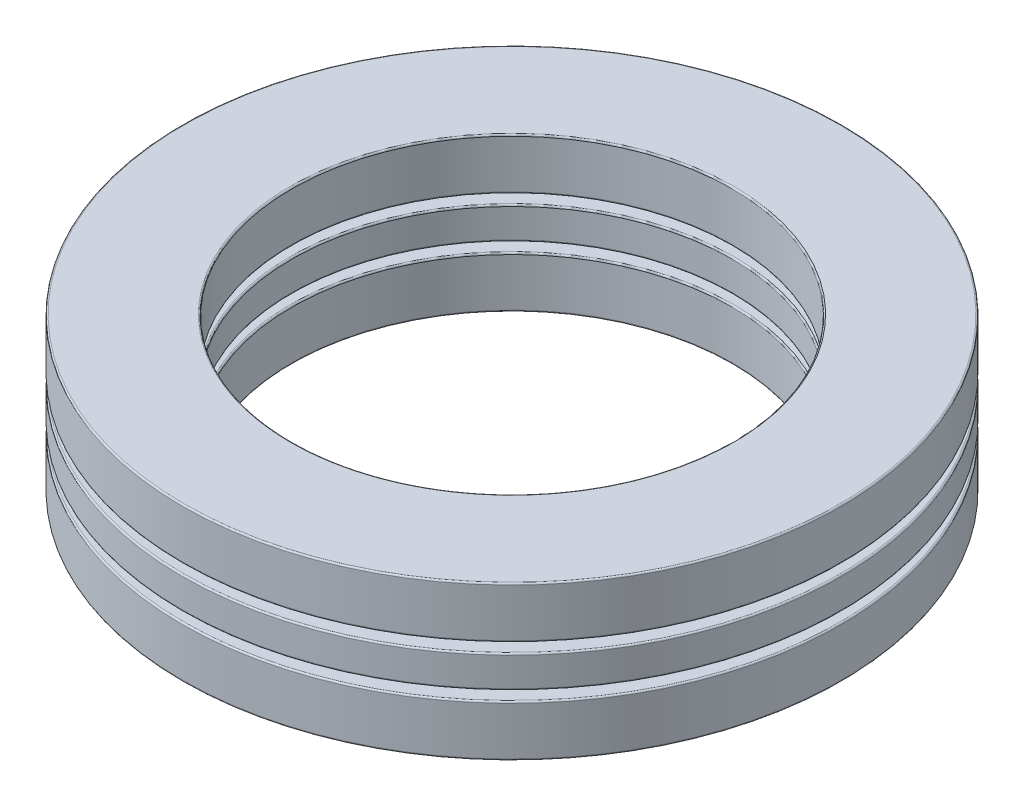
from build123d import *

# Parameters (mm, degrees)
SKETCH1_W         = 7.8994
SKETCH1_H         = 2.312458334
CIRPATTERN1_COUNT = 9
CIRPATTERN1_ANGLE = 320
CIRPATTERN2_COUNT = 9
SKETCH4_W         = 7.8994
SKETCH4_H         = 3.699933333
FILLET1_R         = 0.110998
FILLET2_R         = 0.110998
FILLET3_R         = 0.110998


with BuildPart() as part:
    # Sketch1 → Revolve1 (revolve)
    with BuildSketch(Plane(origin=(0, 0, 0), x_dir=(0, 0, -1), z_dir=(1, 0, 0))):
        with Locations((-19.8628, 0)):
            Rectangle(SKETCH1_W, SKETCH1_H)
    revolve(axis=Axis((0, -5.5499, 0), (0, 1, 0)))

    # Sketch3 → Cut-Revolve1 (revolve, cut)
    with BuildSketch(Plane(origin=(0, 0, 0), x_dir=(0, 0, -1), z_dir=(1, 0, 0))):
        with BuildLine():
            Line((-19.8628, 1.849966667), (-19.8628, -1.849966667))
            ThreePointArc((-19.8628, -1.849966667), (-21.712766667, 0), (-19.8628, 1.849966667))
        make_face()
    cut_revolve1 = revolve(axis=Axis((0, 1.849966667, 19.8628), (0, -1, 0)), mode=Mode.SUBTRACT)

    # CirPattern2: Cut-Revolve1 ×9 about axis
    cirpattern2_axis = Axis((0, 0, 0), (0, 1, 0))
    for i in range(1, CIRPATTERN2_COUNT):
        add(cut_revolve1.rotate(cirpattern2_axis, i * 360 / CIRPATTERN2_COUNT), mode=Mode.SUBTRACT)

    # Fillet2
    fillet2_edges = [part.edges().sort_by_distance(p)[0] for p in [
        (0, 1.156229167, -23.8125),
        (0, 1.156229167, -15.9131),
        (0, -1.156229167, -15.9131),
        (0, -1.156229167, -23.8125),
    ]]
    fillet(fillet2_edges, radius=FILLET2_R)


with BuildPart() as body_2:
    # Sketch2 → Revolve2 (revolve)
    with BuildSketch(Plane(origin=(0, 0, 0), x_dir=(0, 0, -1), z_dir=(1, 0, 0))):
        with BuildLine():
            Line((-19.8628, 1.849966667), (-19.8628, -1.849966667))
            ThreePointArc((-19.8628, -1.849966667), (-21.712766667, 0), (-19.8628, 1.849966667))
        make_face()
    revolve(axis=Axis((0, 1.849966667, 19.8628), (0, -1, 0)))


with BuildPart() as cirpattern1_1:
    # CirPattern1: pattern copy
    add(body_2.part.rotate(Axis((0, 5.5499, 0), (0, -1, 0)), 1 * CIRPATTERN1_ANGLE / (CIRPATTERN1_COUNT - 1)))


with BuildPart() as cirpattern1_2:
    # CirPattern1: pattern copy
    add(body_2.part.rotate(Axis((0, 5.5499, 0), (0, -1, 0)), 2 * CIRPATTERN1_ANGLE / (CIRPATTERN1_COUNT - 1)))


with BuildPart() as cirpattern1_3:
    # CirPattern1: pattern copy
    add(body_2.part.rotate(Axis((0, 5.5499, 0), (0, -1, 0)), 3 * CIRPATTERN1_ANGLE / (CIRPATTERN1_COUNT - 1)))


with BuildPart() as cirpattern1_4:
    # CirPattern1: pattern copy
    add(body_2.part.rotate(Axis((0, 5.5499, 0), (0, -1, 0)), 4 * CIRPATTERN1_ANGLE / (CIRPATTERN1_COUNT - 1)))


with BuildPart() as cirpattern1_5:
    # CirPattern1: pattern copy
    add(body_2.part.rotate(Axis((0, 5.5499, 0), (0, -1, 0)), 5 * CIRPATTERN1_ANGLE / (CIRPATTERN1_COUNT - 1)))


with BuildPart() as cirpattern1_6:
    # CirPattern1: pattern copy
    add(body_2.part.rotate(Axis((0, 5.5499, 0), (0, -1, 0)), 6 * CIRPATTERN1_ANGLE / (CIRPATTERN1_COUNT - 1)))


with BuildPart() as cirpattern1_7:
    # CirPattern1: pattern copy
    add(body_2.part.rotate(Axis((0, 5.5499, 0), (0, -1, 0)), 7 * CIRPATTERN1_ANGLE / (CIRPATTERN1_COUNT - 1)))


with BuildPart() as cirpattern1_8:
    # CirPattern1: pattern copy
    add(body_2.part.rotate(Axis((0, 5.5499, 0), (0, -1, 0)), 8 * CIRPATTERN1_ANGLE / (CIRPATTERN1_COUNT - 1)))


with BuildPart() as body_11:
    # Sketch4 → Revolve3 (revolve)
    with BuildSketch(Plane(origin=(0, 0, 0), x_dir=(0, 0, -1), z_dir=(1, 0, 0))):
        with Locations((-19.8628, 3.699933334)):
            Rectangle(SKETCH4_W, SKETCH4_H)
        with Locations((-19.8628, -3.699933334)):
            Rectangle(SKETCH4_W, SKETCH4_H)
    revolve(axis=Axis((0, -5.5499, 0), (0, 1, 0)))

    # Fillet1
    fillet1_edges = [body_11.edges().sort_by_distance(p)[0] for p in [
        (0, 1.849966667, -23.8125),
        (0, 1.849966667, -15.9131),
        (0, 5.5499, -15.9131),
        (0, 5.5499, -23.8125),
    ]]
    fillet(fillet1_edges, radius=FILLET1_R)

    # Fillet3
    fillet3_edges = [body_11.edges().sort_by_distance(p)[0] for p in [
        (0, -5.5499, -23.8125),
        (0, -5.5499, -15.9131),
        (0, -1.849966667, -15.9131),
        (0, -1.849966667, -23.8125),
    ]]
    fillet(fillet3_edges, radius=FILLET3_R)


solid = Compound([part.part, body_2.part, cirpattern1_1.part, cirpattern1_2.part, cirpattern1_3.part, cirpattern1_4.part, cirpattern1_5.part, cirpattern1_6.part, cirpattern1_7.part, cirpattern1_8.part, body_11.part])
